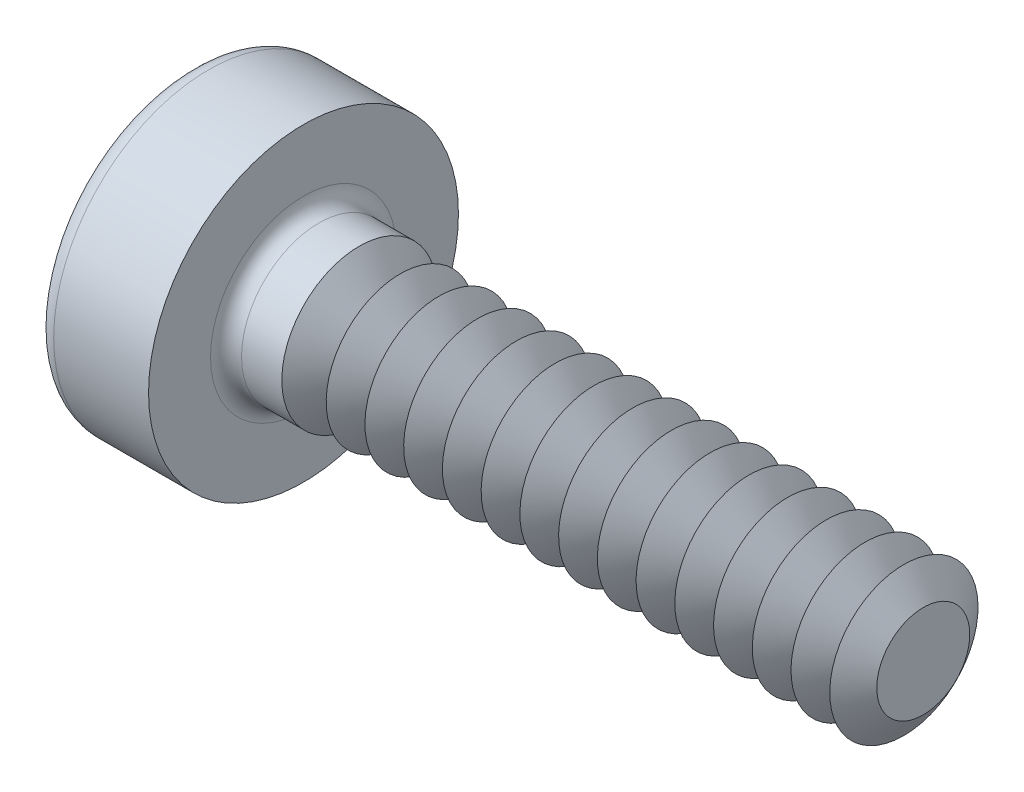
from build123d import *

# Parameters (mm, degrees)
FILLET1_R       = 0.1
SKETCH3_W       = 0.48
SKETCH3_H       = 1.6
SKETCH4_W       = 0.48
SKETCH4_H       = 1.101418476
RECPAT_COUNT    = 2
RECPAT_ANGLE    = 90
THDSCHPAT_COUNT = 15
THDSCHPAT_PITCH = 0.25


with BuildPart() as part:
    # BodySke → Base-Revolve (revolve)
    with BuildSketch(Plane.XY):
        with BuildLine():
            Line((1, 0.5), (1, 1))
            Line((1, 1), (0.387750024, 1))
            ThreePointArc((0.387750024, 1), (0.331271059, 0.985877885), (0.288085469, 0.946835443))
            ThreePointArc((0.288085469, 0.946835443), (0.073615251, 0.494846086), (0, 0))
            Line((0, 0), (5, 0))
            Line((5, 0), (5, 0.5))
            Line((5, 0.5), (1, 0.5))
        make_face()
    revolve(axis=Axis((-25.4, 0, 0), (1, 0, 0)))

    # Fillet1
    fillet1_edges = [part.edges().sort_by_distance(p)[0] for p in [
        (1, -0.5, 0),
    ]]
    fillet(fillet1_edges, radius=FILLET1_R)

    # Sketch3 → Recess section 0
    with BuildSketch(Plane(origin=(0, 0, 0), x_dir=(0, 0, -1), z_dir=(1, 0, 0))):
        Rectangle(SKETCH3_W, SKETCH3_H)
    # Sketch4 → Recess section 1
    with BuildSketch(Plane(origin=(0.5, 0, 0), x_dir=(0, 0, -1), z_dir=(1, 0, 0))):
        Rectangle(SKETCH4_W, SKETCH4_H)
    recess = loft(mode=Mode.SUBTRACT)

    # RecPat: Recess ×2 about axis
    recpat_axis = Axis((0, 0, 0), (1, 0, 0))
    for i in range(1, RECPAT_COUNT):
        add(recess.rotate(recpat_axis, i * RECPAT_ANGLE / (RECPAT_COUNT - 1)), mode=Mode.SUBTRACT)

    # RecCorSke → RecessCore (revolve, cut)
    with BuildSketch(Plane.XY):
        Polygon((0, 0), (0, 0.390463406), (0.5, 0.3555), (0.615508952, 0), align=None)
    revolve(axis=Axis((-3.175, 0, 0), (1, 0, 0)), mode=Mode.SUBTRACT)

    # ThdSchSke → ThreadSchematic (revolve, cut)
    with BuildSketch(Plane.XY):
        Polygon((1.5, -0.3), (1.359958492, -0.5), (1.359958492, -0.625), (1.640041508, -0.625), (1.640041508, -0.5), align=None)
    threadschematic = revolve(axis=Axis((-3.175, 0, 0), (1, 0, 0)), mode=Mode.SUBTRACT)

    # ThdSchPat: ThreadSchematic ×15
    with Locations(*[(i * THDSCHPAT_PITCH, 0, 0) for i in range(1, THDSCHPAT_COUNT)]):
        add(threadschematic, mode=Mode.SUBTRACT)


solid = part.part
